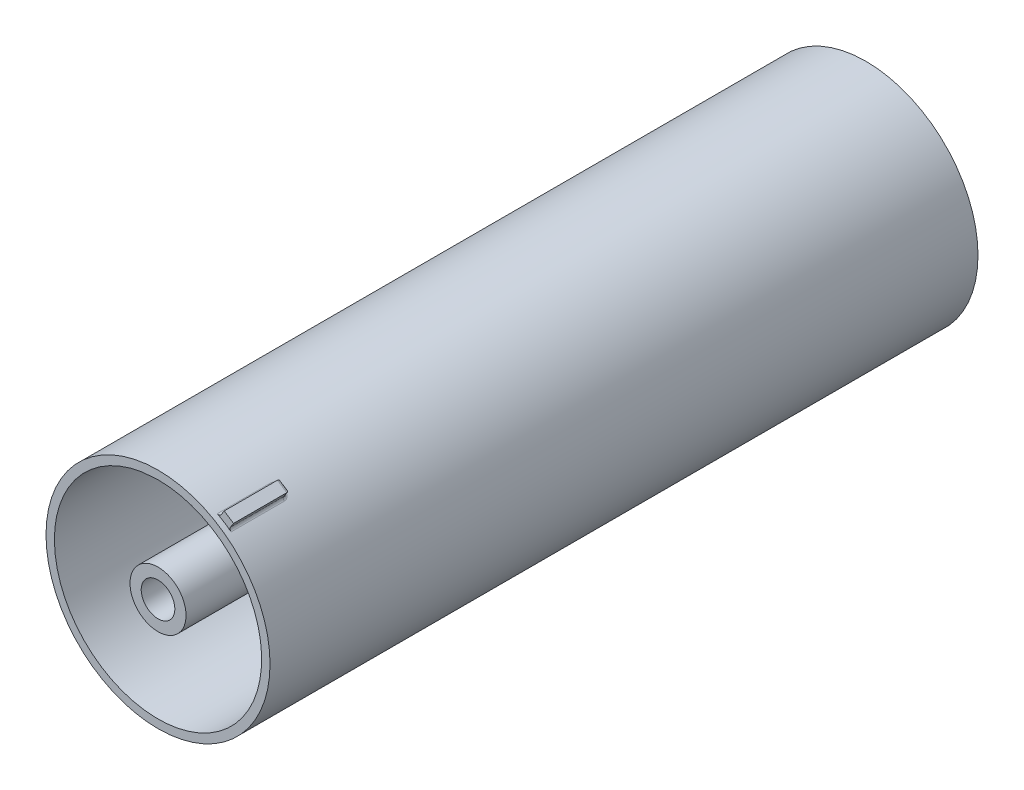
from build123d import *

# Parameters (mm, degrees)
SKETCH_2_R          = 20
SKETCH_2_R_2        = 18.5
EXTRUDE_1_DEPTH     = 126.4
SKETCH_5_R          = 3
EXTRUDE_3_DEPTH     = 126.4
CUT_EXTRUDE1_DEPTH  = 59
CUT_EXTRUDE2_DEPTH  = 59
SKETCH3_R           = 5
SKETCH3_R_2         = 3
BOSS_EXTRUDE1_DEPTH = 58.6
BOSS_EXTRUDE2_START = -1
BOSS_EXTRUDE2_DEPTH = 10
FILLET1_R           = 0.5


with BuildPart() as part:
    # Эскиз2 → Бобышка-Вытянуть1 (new body)
    with BuildSketch(Plane.XY):
        Circle(SKETCH_2_R)
        Circle(SKETCH_2_R_2, mode=Mode.SUBTRACT)
    extrude(amount=EXTRUDE_1_DEPTH)

    # Эскиз5 → Бобышка-Вытянуть3 (add, through all)
    with BuildSketch(Plane(origin=(0, 0, 0), x_dir=(-1, 0, 0), z_dir=(0, 0, -1))):
        with BuildLine():
            Line((0, 18.5), (0, 9.219544457))
            ThreePointArc((0, 9.219544457), (-0.725705562, 6.35915669), (-2.727272727, 4.190702026))
            ThreePointArc((-2.727272727, 4.190702026), (-0.405405405, -4.983537544), (3.368749585, 3.694797184))
            ThreePointArc((3.368749585, 3.694797184), (1.743983113, 6.158250179), (1.490138787, 9.098323274))
            Line((1.490138787, 9.098323274), (2.990122527, 18.256756757))
            ThreePointArc((2.990122527, 18.256756757), (1.5, 18.439088915), (0, 18.5))
        make_face()
        Circle(SKETCH_5_R, mode=Mode.SUBTRACT)
    extrude(amount=-EXTRUDE_3_DEPTH)

    # Sketch1 → Cut-Extrude1 (cut)
    with BuildSketch(Plane(origin=(0, 0, 0), x_dir=(-1, 0, 0), z_dir=(0, 0, -1))):
        with BuildLine():
            Line((0, 18.5), (2.990122527, 18.256756757))
            ThreePointArc((2.990122527, 18.256756757), (-1.5, -18.439088915), (0, 18.5))
        make_face()
    extrude(amount=-CUT_EXTRUDE1_DEPTH, mode=Mode.SUBTRACT)

    # Sketch2 → Cut-Extrude2 (cut)
    with BuildSketch(Plane.XY.offset(126.4)):
        with BuildLine():
            Line((0, 18.5), (-2.990122527, 18.256756757))
            ThreePointArc((-2.990122527, 18.256756757), (1.50000041, -18.439093959), (0, 18.5))
        make_face()
    extrude(amount=-CUT_EXTRUDE2_DEPTH, mode=Mode.SUBTRACT)

    # Sketch4 → Boss-Extrude2 (add)
    with BuildSketch(Plane.XY.offset(126.4).offset(BOSS_EXTRUDE2_START)):
        Polygon((10, 17.320508076), (11.679884389, 16.235156318), (12.493898208, 17.495069609), (10.814013819, 18.580421368), align=None)
    extrude(amount=-BOSS_EXTRUDE2_DEPTH)

    # Fillet1
    fillet1_edges = [part.edges().sort_by_distance(p)[0] for p in [
        (10.853517582, 16.798843892, 115.4),
        (10.407006909, 17.950464722, 115.4),
        (10, 17.320508076, 120.4),
        (11.653956013, 18.037745489, 115.4),
        (12.086891299, 16.865112963, 115.4),
        (11.679884389, 16.235156318, 120.4),
    ]]
    fillet(fillet1_edges, radius=FILLET1_R)


with BuildPart() as body_2:
    # Sketch3 → Boss-Extrude1 (new body)
    with BuildSketch(Plane.XY.offset(126.4)):
        Circle(SKETCH3_R)
        Circle(SKETCH3_R_2, mode=Mode.SUBTRACT)
    extrude(amount=-BOSS_EXTRUDE1_DEPTH)


solid = Compound([part.part, body_2.part])
